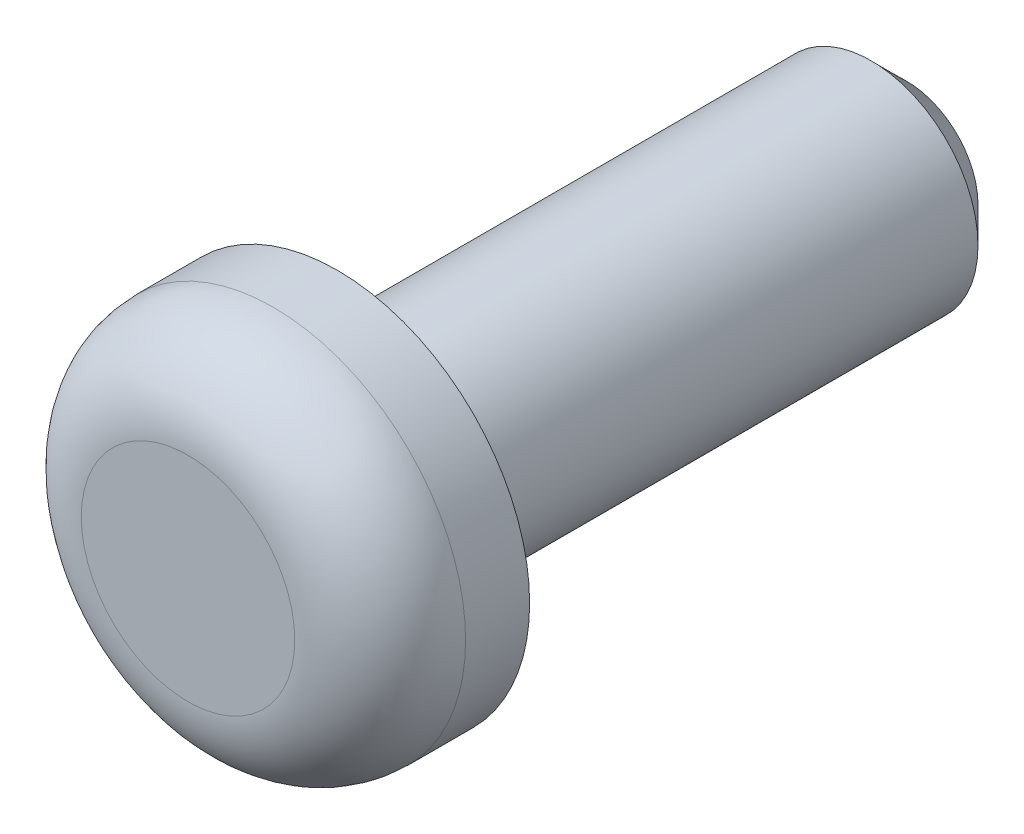
from build123d import *

# Parameters (mm, degrees)
VERRUNDUNG1_R = 1.2
FASE1_SIZE    = 0.5


with BuildPart() as part:
    # Skizze1 → Rotation1 (revolve)
    with BuildSketch(Plane(origin=(0, 0, 0), x_dir=(0, 0, -1), z_dir=(1, 0, 0))):
        Polygon((0, 2.7), (0, 1.5), (8, 1.5), (8, 0), (-2.1, 0), (-2.1, 2.7), align=None)
    revolve(axis=Axis((0, 0, 0), (0, 0, -1)))

    # Verrundung1
    verrundung1_edges = [part.edges().sort_by_distance(p)[0] for p in [
        (0, -2.7, 2.1),
    ]]
    fillet(verrundung1_edges, radius=VERRUNDUNG1_R)

    # Fase1
    fase1_edges = [part.edges().sort_by_distance(p)[0] for p in [
        (0, -1.5, -8),
    ]]
    chamfer(fase1_edges, length=FASE1_SIZE)


solid = part.part
